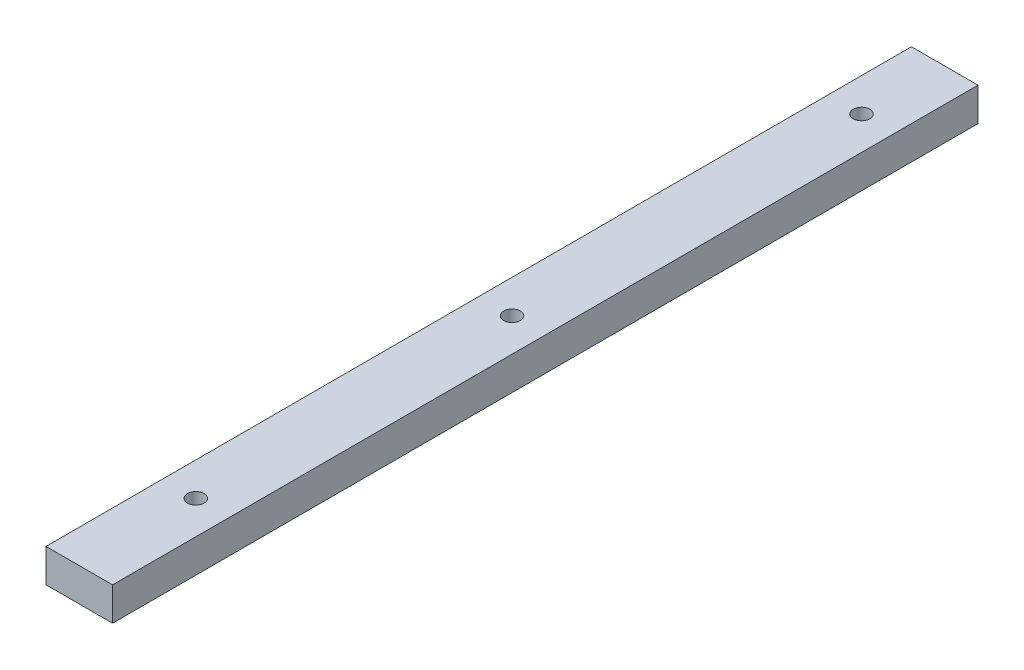
from build123d import *

# Parameters (mm, degrees)
SKETCH1_W           = 50.8
SKETCH1_H           = 25.4
BOSS_EXTRUDE1_DEPTH = 660.4
SKETCH2_R           = 6.35
CUT_EXTRUDE1_DEPTH  = 254


with BuildPart() as part:
    # Sketch1 → Boss-Extrude1 (new body)
    with BuildSketch(Plane.XY):
        with Locations((25.4, 12.7)):
            Rectangle(SKETCH1_W, SKETCH1_H)
    extrude(amount=BOSS_EXTRUDE1_DEPTH)

    # Sketch2 → Cut-Extrude1 (cut)
    with BuildSketch(Plane(origin=(0, 25.4, 0), x_dir=(1, 0, 0), z_dir=(0, 1, 0))):
        with Locations((25.4, -63.5)):
            Circle(SKETCH2_R)
        with Locations((25.4, -571.5)):
            Circle(SKETCH2_R)
        with Locations((25.4, -330.2)):
            Circle(SKETCH2_R)
    extrude(amount=-CUT_EXTRUDE1_DEPTH, mode=Mode.SUBTRACT)


solid = part.part
